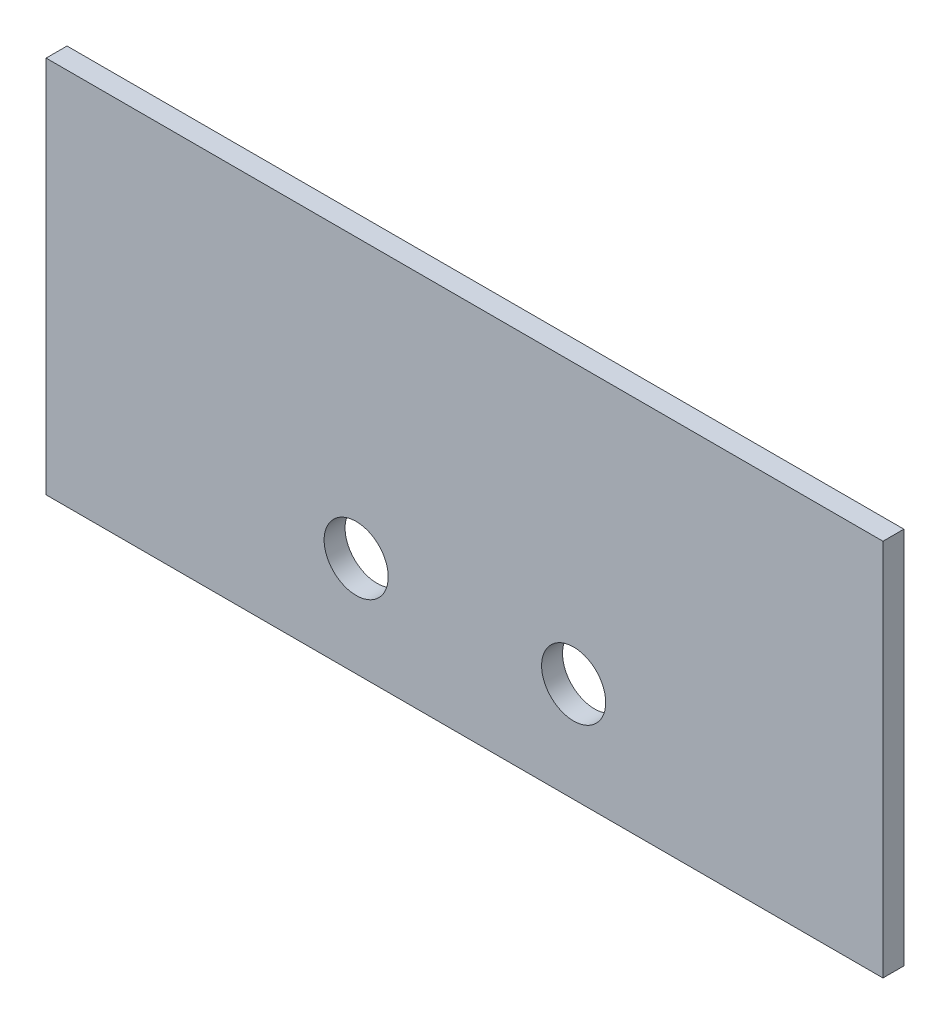
from build123d import *

# Parameters (mm, degrees)
SKETCH1_W           = 127
SKETCH1_H           = 57.404
SKETCH1_R           = 4.864
BOSS_EXTRUDE1_DEPTH = 3.175


with BuildPart() as part:
    # Sketch1 → Boss-Extrude1 (new body)
    with BuildSketch(Plane.XY):
        with Locations((63.5, 28.702)):
            Rectangle(SKETCH1_W, SKETCH1_H)
        with Locations((80.056, 15.167)):
            Circle(SKETCH1_R, mode=Mode.SUBTRACT)
        with Locations((47.056, 15.167)):
            Circle(SKETCH1_R, mode=Mode.SUBTRACT)
    extrude(amount=BOSS_EXTRUDE1_DEPTH)


solid = part.part
